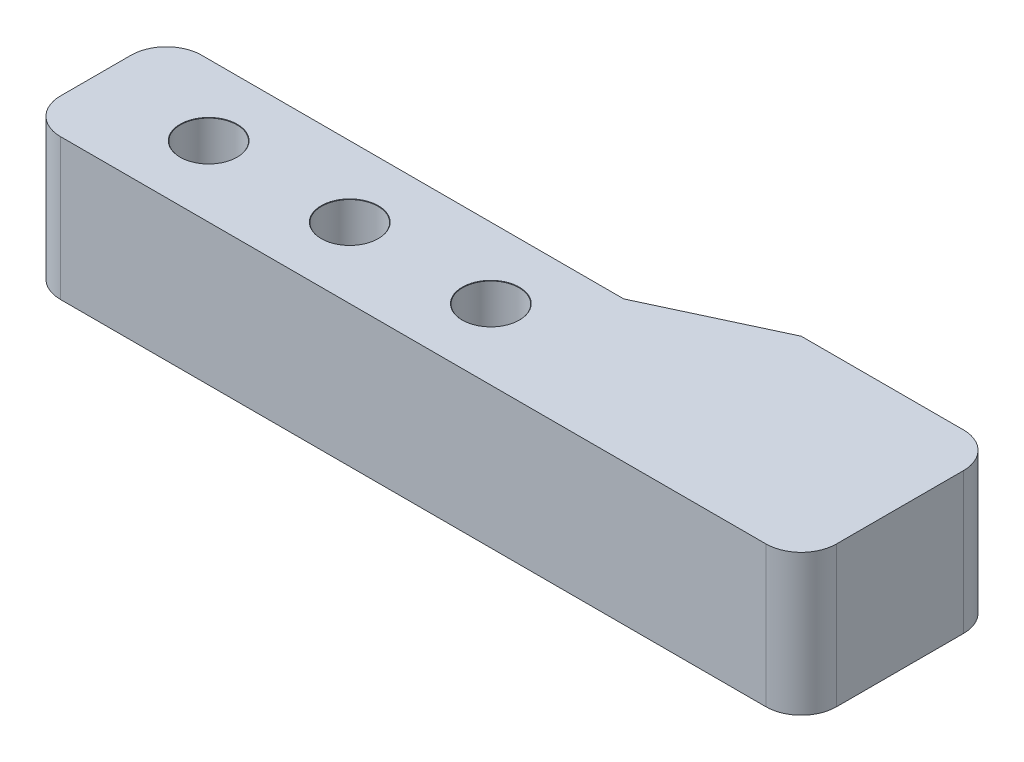
from build123d import *

# Parameters (mm, degrees)
BOSS_EXTRUDE1_DEPTH             = 10
F_4_0MM_DOWEL_HOLE1_D           = 4
F_4_0MM_DOWEL_HOLE1_CSINK_D     = 4.05
F_4_0MM_DOWEL_HOLE1_CSINK_ANGLE = 90
CUT_EXTRUDE1_DEPTH              = 3
FILLET1_R                       = 2.5


with BuildPart() as part:
    # Sketch1 → Boss-Extrude1 (new body)
    with BuildSketch(Plane(origin=(0, 0, 0), x_dir=(1, 0, 0), z_dir=(0, 1, 0))):
        Polygon((0, 5), (0, -5), (55, -5), (55, 9), (41, 9), (32.421972318, 5), align=None)
    extrude(amount=BOSS_EXTRUDE1_DEPTH)

    # Ø4.0mm Dowel Hole1 (through all)
    with Locations(Plane(origin=(0, 10, 0), x_dir=(1, 0, 0), z_dir=(0, 1, 0))):
        with Locations((8, 0), (18, 0), (28, 0)):
            CounterSinkHole(F_4_0MM_DOWEL_HOLE1_D / 2, F_4_0MM_DOWEL_HOLE1_CSINK_D / 2, counter_sink_angle=F_4_0MM_DOWEL_HOLE1_CSINK_ANGLE)

    # Sketch5 → Cut-Extrude1 (cut)
    with BuildSketch(Plane.XZ):
        Polygon((9.75, -3.031088913), (11.5, 0), (9.75, 3.031088913), (6.25, 3.031088913), (4.5, 0), (6.25, -3.031088913), align=None)
        Polygon((21.5, 0), (19.75, 3.031088913), (16.25, 3.031088913), (14.5, 0), (16.25, -3.031088913), (19.75, -3.031088913), align=None)
        Polygon((31.5, 0), (29.75, 3.031088913), (26.25, 3.031088913), (24.5, 0), (26.25, -3.031088913), (29.75, -3.031088913), align=None)
    extrude(amount=-CUT_EXTRUDE1_DEPTH, mode=Mode.SUBTRACT)

    # Fillet1
    fillet1_edges = [part.edges().sort_by_distance(p)[0] for p in [
        (55, 5, -9),
        (55, 5, 5),
        (0, 5, 5),
        (0, 5, -5),
    ]]
    fillet(fillet1_edges, radius=FILLET1_R)


solid = part.part
